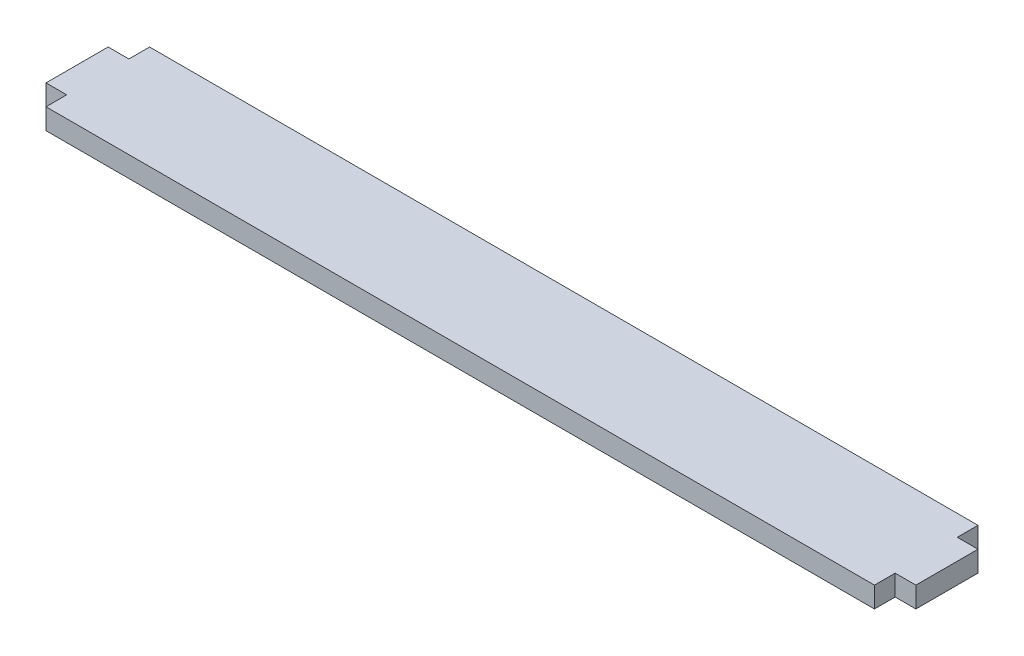
from build123d import *

# Parameters (mm, degrees)
BOSS_EXTRUDE1_DEPTH = 3.175


with BuildPart() as part:
    # Sketch1 → Boss-Extrude1 (new body)
    with BuildSketch(Plane(origin=(0, 0, 0), x_dir=(1, 0, 0), z_dir=(0, 1, 0))):
        Polygon((-63.5, -7.9375), (63.5, -7.9375), (63.5, -4.7625), (66.675, -4.7625), (66.675, 4.7625), (63.5, 4.7625), (63.5, 7.9375), (-63.5, 7.9375), (-63.5, 4.7625), (-66.675, 4.7625), (-66.675, -4.7625), (-63.5, -4.7625), align=None)
    extrude(amount=BOSS_EXTRUDE1_DEPTH)


solid = part.part
